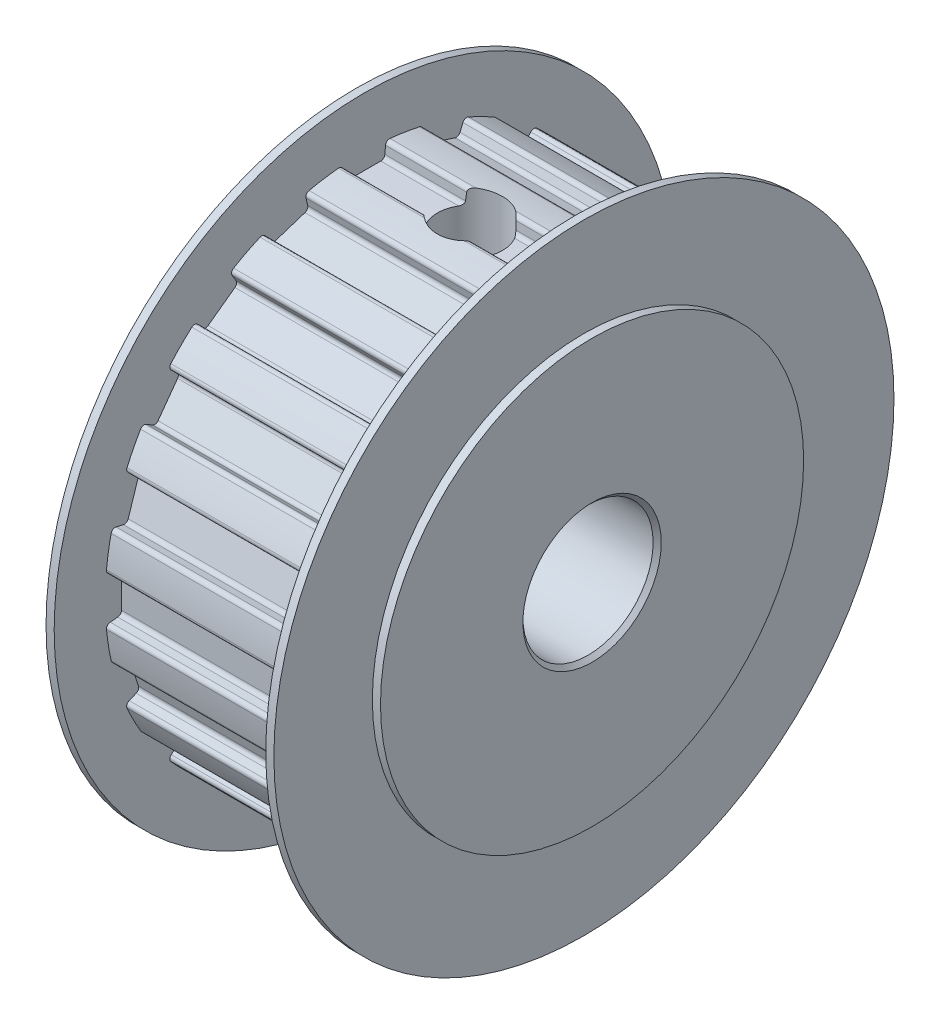
from build123d import *

# Parameters (mm, degrees)
ESQUISSE1_R                         = 15.915
EXTRUSION1_DEPTH                    = 13
ENL_V_MAT_EXTRU_2_DEPTH             = 13
CONG_1_R                            = 0.25
CONG_2_R                            = 0.25
CONG_3_R                            = 0.25
CONG_4_R                            = 0.25
R_P_TITION_CIRCULAIRE1_COUNT        = 20
CONG_1_OF_R_P_TITION_CIRCULAIRE1_R  = 0.25
CONG_2_OF_R_P_TITION_CIRCULAIRE1_R  = 0.25
CONG_3_OF_R_P_TITION_CIRCULAIRE1_R  = 0.25
CONG_4_OF_R_P_TITION_CIRCULAIRE1_R  = 0.25
ESQUISSE23_R                        = 19.05
EXTRUSION2_DEPTH                    = 1
ESQUISSE24_R                        = 19.05
EXTRUSION3_DEPTH                    = 1
ESQUISSE25_R                        = 4
ENL_V_MAT_EXTRU_3_DEPTH             = 16
ENL_V_MAT_EXTRU_5_REACH             = 35.965
ESQUISSE30_R                        = 2
ENL_V_MAT_EXTRU_5_DIRECTION_2_DEPTH = 5.135
ESQUISSE31_OUTSIDE_W                = 51.286
ESQUISSE31_OUTSIDE_H                = 51.286
ESQUISSE31_OUTSIDE_R                = 13
ENL_V_MAT_EXTRU_6_DEPTH             = 0.5
ESQUISSE32_OUTSIDE_W                = 51.286
ESQUISSE32_OUTSIDE_H                = 51.286
ESQUISSE32_OUTSIDE_R                = 13
ENL_V_MAT_EXTRU_7_DEPTH             = 0.5
CHANFREIN1_SIZE                     = 0.25
CHANFREIN2_SIZE                     = 0.25


with BuildPart() as part:
    # Esquisse1 → Extrusion1 (new body)
    with BuildSketch(Plane(origin=(0, 0, 0), x_dir=(0, 0, -1), z_dir=(1, 0, 0))):
        Circle(ESQUISSE1_R)
    extrude(amount=EXTRUSION1_DEPTH)

    # Esquisse22 → Enlèv. mat.-Extru.2 (cut)
    with BuildSketch(Plane.ZY):
        Polygon((-1.25, 14.915), (1.25, 14.915), (2.12662356, 25.374872317), (-2.12713714, 25.381000349), align=None)
    enl_v_mat_extru_2 = extrude(amount=-ENL_V_MAT_EXTRU_2_DEPTH, mode=Mode.SUBTRACT)

    # Congé1
    cong_1_edges = [part.edges().sort_by_distance(p)[0] for p in [
        (6.5, 14.915, -1.25),
    ]]
    fillet(cong_1_edges, radius=CONG_1_R)

    # Congé2
    cong_2_edges = [part.edges().sort_by_distance(p)[0] for p in [
        (6.5, 15.859400654, -1.329148563),
    ]]
    fillet(cong_2_edges, radius=CONG_2_R)

    # Congé3
    cong_3_edges = [part.edges().sort_by_distance(p)[0] for p in [
        (6.5, 14.915, 1.25),
    ]]
    fillet(cong_3_edges, radius=CONG_3_R)

    # Congé4
    cong_4_edges = [part.edges().sort_by_distance(p)[0] for p in [
        (6.5, 15.859400654, 1.329148563),
    ]]
    fillet(cong_4_edges, radius=CONG_4_R)

    # Répétition circulaire1: Enlèv. mat.-Extru.2 ×20 about axis
    r_p_tition_circulaire1_axis = Axis((0, 0, 0), (1, 0, 0))
    for i in range(1, R_P_TITION_CIRCULAIRE1_COUNT):
        add(enl_v_mat_extru_2.rotate(r_p_tition_circulaire1_axis, i * 360 / R_P_TITION_CIRCULAIRE1_COUNT), mode=Mode.SUBTRACT)

    # Congé1 of Répétition circulaire1
    cong_1_of_r_p_tition_circulaire1_edges = [part.edges().sort_by_distance(p)[0] for p in [
        (6.5, 14.571279184, 3.420167826),
        (6.5, 12.801220036, 7.755545795),
        (6.5, 9.778088281, 11.331756906),
        (6.5, 5.797809116, 13.798736698),
        (6.5, 1.25, 14.915),
        (6.5, -3.420167826, 14.571279184),
        (6.5, -7.755545795, 12.801220036),
        (6.5, -11.331756906, 9.778088281),
        (6.5, -13.798736698, 5.797809116),
        (6.5, -14.915, 1.25),
        (6.5, -14.571279184, -3.420167826),
        (6.5, -12.801220036, -7.755545795),
        (6.5, -9.778088281, -11.331756906),
        (6.5, -5.797809116, -13.798736698),
        (6.5, -1.25, -14.915),
        (6.5, 3.420167826, -14.571279184),
        (6.5, 7.755545795, -12.801220036),
        (6.5, 11.331756906, -9.778088281),
        (6.5, 13.798736698, -5.797809116),
    ]]
    fillet(cong_1_of_r_p_tition_circulaire1_edges, radius=CONG_1_OF_R_P_TITION_CIRCULAIRE1_R)

    # Congé2 of Répétition circulaire1
    cong_2_of_r_p_tition_circulaire1_edges = [part.edges().sort_by_distance(p)[0] for p in [
        (6.5, 15.49391583, 3.636728921),
        (6.5, 13.611778573, 8.246618039),
        (6.5, 10.39722559, 12.049270726),
        (6.5, 6.164919725, 14.672456842),
        (6.5, 1.329148563, 15.859400654),
        (6.5, -3.636728921, 15.49391583),
        (6.5, -8.246618039, 13.611778573),
        (6.5, -12.049270726, 10.39722559),
        (6.5, -14.672456842, 6.164919725),
        (6.5, -15.859400654, 1.329148563),
        (6.5, -15.49391583, -3.636728921),
        (6.5, -13.611778573, -8.246618039),
        (6.5, -10.39722559, -12.049270726),
        (6.5, -6.164919725, -14.672456842),
        (6.5, -1.329148563, -15.859400654),
        (6.5, 3.636728921, -15.49391583),
        (6.5, 8.246618039, -13.611778573),
        (6.5, 12.049270726, -10.39722559),
        (6.5, 14.672456842, -6.164919725),
    ]]
    fillet(cong_2_of_r_p_tition_circulaire1_edges, radius=CONG_2_OF_R_P_TITION_CIRCULAIRE1_R)

    # Congé3 of Répétition circulaire1
    cong_3_of_r_p_tition_circulaire1_edges = [part.edges().sort_by_distance(p)[0] for p in [
        (6.5, 13.798736698, 5.797809116),
        (6.5, 11.331756906, 9.778088281),
        (6.5, 7.755545795, 12.801220036),
        (6.5, 3.420167826, 14.571279184),
        (6.5, -1.25, 14.915),
        (6.5, -5.797809116, 13.798736698),
        (6.5, -9.778088281, 11.331756906),
        (6.5, -12.801220036, 7.755545795),
        (6.5, -14.571279184, 3.420167826),
        (6.5, -14.915, -1.25),
        (6.5, -13.798736698, -5.797809116),
        (6.5, -11.331756906, -9.778088281),
        (6.5, -7.755545795, -12.801220036),
        (6.5, -3.420167826, -14.571279184),
        (6.5, 1.25, -14.915),
        (6.5, 5.797809116, -13.798736698),
        (6.5, 9.778088281, -11.331756906),
        (6.5, 12.801220036, -7.755545795),
        (6.5, 14.571279184, -3.420167826),
    ]]
    fillet(cong_3_of_r_p_tition_circulaire1_edges, radius=CONG_3_OF_R_P_TITION_CIRCULAIRE1_R)

    # Congé4 of Répétition circulaire1
    cong_4_of_r_p_tition_circulaire1_edges = [part.edges().sort_by_distance(p)[0] for p in [
        (6.5, 14.672456842, 6.164919725),
        (6.5, 12.049270726, 10.39722559),
        (6.5, 8.246618039, 13.611778573),
        (6.5, 3.636728921, 15.49391583),
        (6.5, -1.329148563, 15.859400654),
        (6.5, -6.164919725, 14.672456842),
        (6.5, -10.39722559, 12.049270726),
        (6.5, -13.611778573, 8.246618039),
        (6.5, -15.49391583, 3.636728921),
        (6.5, -15.859400654, -1.329148563),
        (6.5, -14.672456842, -6.164919725),
        (6.5, -12.049270726, -10.39722559),
        (6.5, -8.246618039, -13.611778573),
        (6.5, -3.636728921, -15.49391583),
        (6.5, 1.329148563, -15.859400654),
        (6.5, 6.164919725, -14.672456842),
        (6.5, 10.39722559, -12.049270726),
        (6.5, 13.611778573, -8.246618039),
        (6.5, 15.49391583, -3.636728921),
    ]]
    fillet(cong_4_of_r_p_tition_circulaire1_edges, radius=CONG_4_OF_R_P_TITION_CIRCULAIRE1_R)

    # Esquisse23 → Extrusion2 (add)
    with BuildSketch(Plane.ZY):
        Circle(ESQUISSE23_R)
    extrude(amount=EXTRUSION2_DEPTH)

    # Esquisse24 → Extrusion3 (add)
    with BuildSketch(Plane(origin=(13, 0, 0), x_dir=(0, 0, -1), z_dir=(1, 0, 0))):
        Circle(ESQUISSE24_R)
    extrude(amount=EXTRUSION3_DEPTH)

    # Esquisse25 → Enlèv. mat.-Extru.3 (cut, through all)
    with BuildSketch(Plane.ZY.offset(1)):
        Circle(ESQUISSE25_R)
    extrude(amount=-ENL_V_MAT_EXTRU_3_DEPTH, mode=Mode.SUBTRACT)

    # Esquisse30 → Enlèv. mat.-Extru.5 (cut, up to next)
    with BuildSketch(Plane(origin=(0, 14.915, 0), x_dir=(-1, 0, 0), z_dir=(0, 1, 0)), mode=Mode.PRIVATE) as enl_v_mat_extru_5_sk1:
        with Locations((-6.5, 0)):
            Circle(ESQUISSE30_R)
    enl_v_mat_extru_5_tool1 = extrude(enl_v_mat_extru_5_sk1.sketch, amount=-ENL_V_MAT_EXTRU_5_REACH, mode=Mode.PRIVATE) & part.part
    add(enl_v_mat_extru_5_tool1.solids().sort_by_distance((6.5, 14.915, 0))[0], mode=Mode.SUBTRACT)

    # Esquisse30 → Enlèv. mat.-Extru.5 direction 2 (cut)
    with BuildSketch(Plane(origin=(0, 14.915, 0), x_dir=(-1, 0, 0), z_dir=(0, 1, 0))):
        with Locations((-6.5, 0)):
            Circle(ESQUISSE30_R)
    extrude(amount=ENL_V_MAT_EXTRU_5_DIRECTION_2_DEPTH, mode=Mode.SUBTRACT)

    # Esquisse31 outside → Enlèv. mat.-Extru.6 (cut)
    with BuildSketch(Plane.ZY.offset(1)):
        Rectangle(ESQUISSE31_OUTSIDE_W, ESQUISSE31_OUTSIDE_H)
        Circle(ESQUISSE31_OUTSIDE_R, mode=Mode.SUBTRACT)
    extrude(amount=-ENL_V_MAT_EXTRU_6_DEPTH, mode=Mode.SUBTRACT)

    # Esquisse32 outside → Enlèv. mat.-Extru.7 (cut)
    with BuildSketch(Plane(origin=(14, 0, 0), x_dir=(0, 0, -1), z_dir=(1, 0, 0))):
        Rectangle(ESQUISSE32_OUTSIDE_W, ESQUISSE32_OUTSIDE_H)
        Circle(ESQUISSE32_OUTSIDE_R, mode=Mode.SUBTRACT)
    extrude(amount=-ENL_V_MAT_EXTRU_7_DEPTH, mode=Mode.SUBTRACT)

    # Chanfrein1
    chanfrein1_edges = [part.edges().sort_by_distance(p)[0] for p in [
        (14, 0, -4),
    ]]
    chamfer(chanfrein1_edges, length=CHANFREIN1_SIZE)

    # Chanfrein2
    chanfrein2_edges = [part.edges().sort_by_distance(p)[0] for p in [
        (-1, 0, -4),
    ]]
    chamfer(chanfrein2_edges, length=CHANFREIN2_SIZE)


solid = part.part
